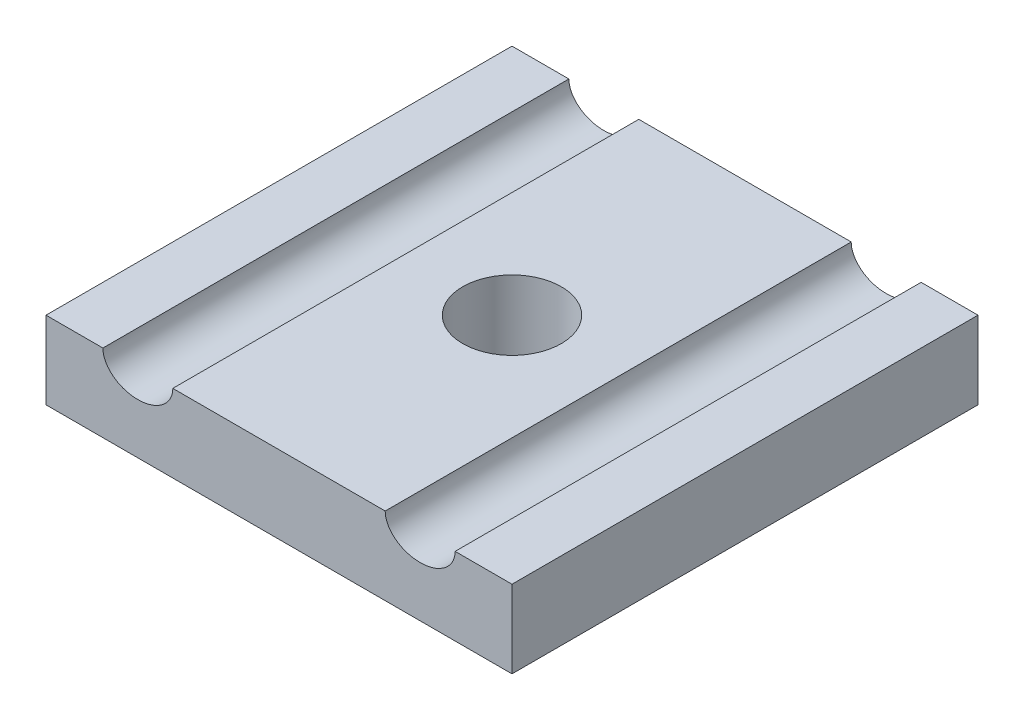
from build123d import *

# Parameters (mm, degrees)
SKETCH1_W           = 30
SKETCH1_H           = 30
BOSS_EXTRUDE1_DEPTH = 5
SKETCH2_R           = 3.175
CUT_EXTRUDE1_DEPTH  = 5
SKETCH3_RX          = 2.25
SKETCH3_RY          = 1.75
CUT_EXTRUDE3_DEPTH  = 30


with BuildPart() as part:
    # Sketch1 → Boss-Extrude1 (new body)
    with BuildSketch(Plane(origin=(0, 0, 0), x_dir=(1, 0, 0), z_dir=(0, 1, 0))):
        with Locations((-15, -15)):
            Rectangle(SKETCH1_W, SKETCH1_H)
    extrude(amount=BOSS_EXTRUDE1_DEPTH)

    # Sketch2 → Cut-Extrude1 (cut)
    with BuildSketch(Plane(origin=(0, 5, 0), x_dir=(1, 0, 0), z_dir=(0, 1, 0))):
        with Locations((-15, -15)):
            Circle(SKETCH2_R)
    extrude(amount=-CUT_EXTRUDE1_DEPTH, mode=Mode.SUBTRACT)

    # Sketch3 → Cut-Extrude3 (cut)
    with BuildSketch(Plane.XY.offset(30)):
        with Locations(Location((-24.0875, 5), (0, 0, 180))):
            Ellipse(SKETCH3_RX, SKETCH3_RY)
        with Locations(Location((-5.9125, 5), (0, 0, 180))):
            Ellipse(SKETCH3_RX, SKETCH3_RY)
    extrude(amount=-CUT_EXTRUDE3_DEPTH, mode=Mode.SUBTRACT)


solid = part.part
